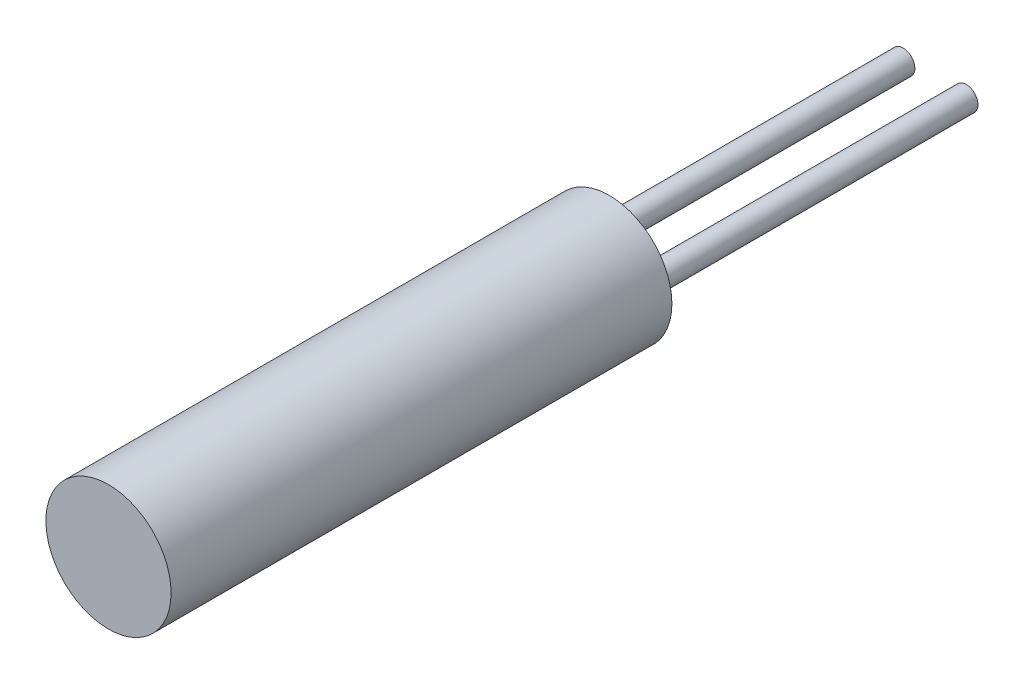
from build123d import *

# Parameters (mm, degrees)
SKETCH1_R           = 3.175
BOSS_EXTRUDE1_DEPTH = 25.4
SKETCH2_R           = 0.6
BOSS_EXTRUDE2_DEPTH = 16.5


with BuildPart() as part:
    # Sketch1 → Boss-Extrude1 (new body)
    with BuildSketch(Plane.XY):
        Circle(SKETCH1_R)
    extrude(amount=BOSS_EXTRUDE1_DEPTH)

    # Sketch2 → Boss-Extrude2 (add)
    with BuildSketch(Plane(origin=(0, 0, 0), x_dir=(-1, 0, 0), z_dir=(0, 0, -1))):
        with Locations((-1.6, 0)):
            Circle(SKETCH2_R)
        with Locations((1.6, 0)):
            Circle(SKETCH2_R)
    extrude(amount=BOSS_EXTRUDE2_DEPTH)


solid = part.part
